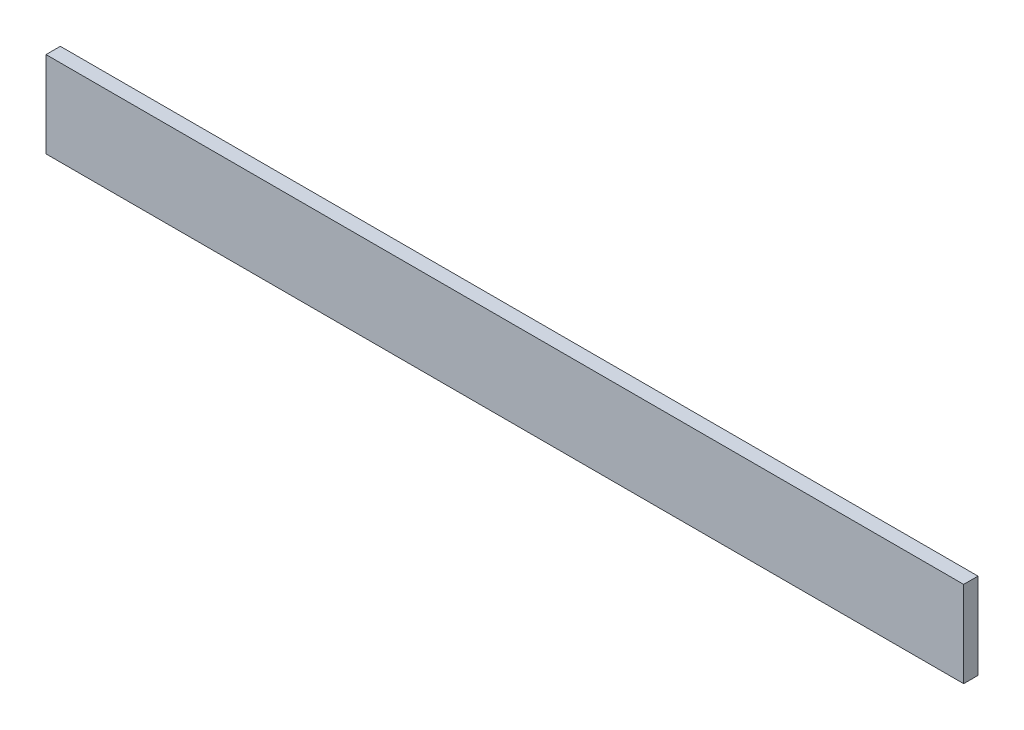
from build123d import *

# Parameters (mm, degrees)
SKETCH2_W           = 406.4
SKETCH2_H           = 38.1
BOSS_EXTRUDE1_DEPTH = 6.35


with BuildPart() as part:
    # Sketch2 → Boss-Extrude1 (new body)
    with BuildSketch(Plane.XY):
        with Locations((0, 19.05)):
            Rectangle(SKETCH2_W, SKETCH2_H)
    extrude(amount=BOSS_EXTRUDE1_DEPTH)


solid = part.part
